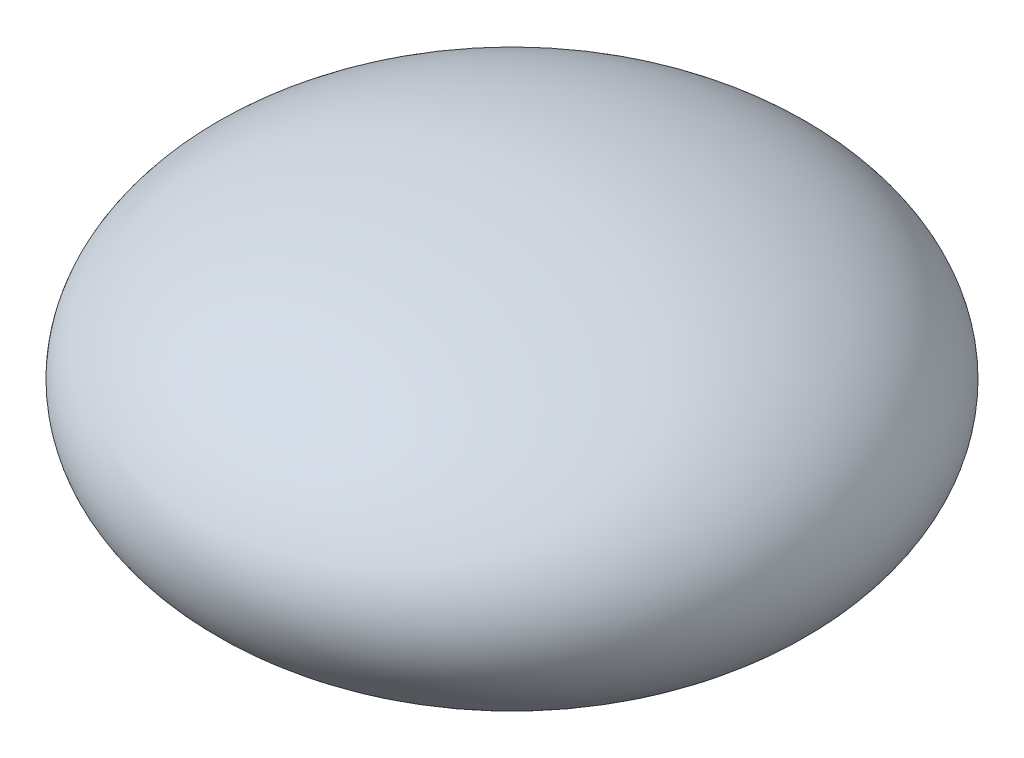
from build123d import *


with BuildPart() as part:
    # Sketch3 → Revolve3 (revolve)
    with BuildSketch(Plane.XY):
        with BuildLine():
            Line((0, 5.5), (0, -5.5))
            add(Edge.make_bspline(
                [(0, -5.5), (10.75, -5.5), (10.75, 0), (10.75, 5.5), (0, 5.5)],
                knots=[4.71238898, 4.71238898, 4.71238898, 6.283185307, 6.283185307, 7.853981634, 7.853981634, 7.853981634], degree=2, weights=[1, 0.707106781, 1, 0.707106781, 1]))
        make_face()
    revolve(axis=Axis((0, 5.5, 0), (0, -1, 0)))


solid = part.part
